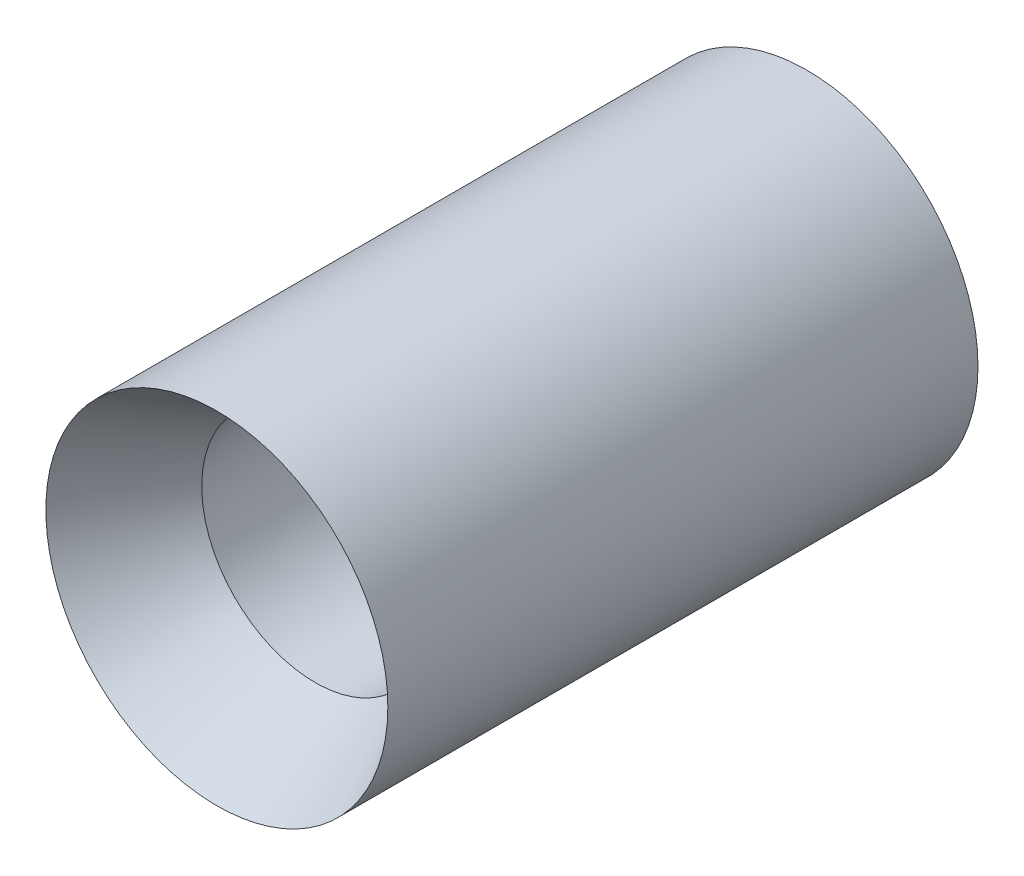
from build123d import *


with BuildPart() as part:
    # Sketch3 → Revolve1 (revolve)
    with BuildSketch(Plane(origin=(0, 0, 0), x_dir=(0, 0, -1), z_dir=(1, 0, 0))):
        Polygon((8.255, 9.525), (27.305, 9.525), (49.53, 14.249069583), (49.53, 14.351), (0, 14.351), align=None)
    revolve(axis=Axis((0, 0, 0), (0, 0, -1)))


solid = part.part
